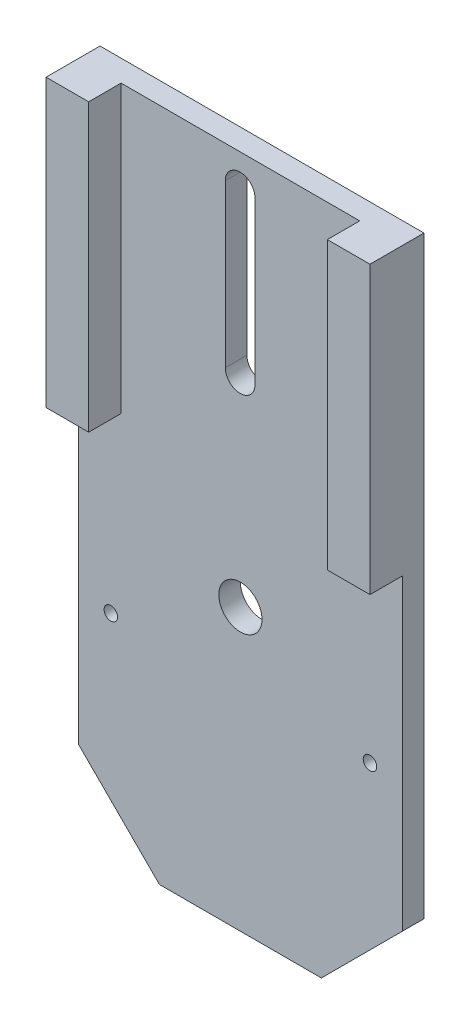
from build123d import *

# Parameters (mm, degrees)
ESQUISSE1_W             = 60
ESQUISSE1_H             = 125
BOSS_EXTRU_1_DEPTH      = 10
ESQUISSE2_R             = 4
ENL_V_MAT_EXTRU_1_DEPTH = 11
ESQUISSE4_W             = 6
ESQUISSE4_H             = 72
ENL_V_MAT_EXTRU_2_DEPTH = 61
TROU_TARAUD_M33_D       = 2.5
TROU_TARAUD_M34_D       = 2.5
CHANFREIN1_SIZE         = 15
ESQUISSE15_W            = 44.2
ESQUISSE15_H            = 6
ENL_V_MAT_EXTRU_4_DEPTH = 55
ENL_V_MAT_EXTRU_5_DEPTH = 11


with BuildPart() as part:
    # Esquisse1 → Boss.-Extru.1 (new body)
    with BuildSketch(Plane.XY):
        with Locations((30, 62.5)):
            Rectangle(ESQUISSE1_W, ESQUISSE1_H)
    extrude(amount=BOSS_EXTRU_1_DEPTH)

    # Esquisse2 → Enlèv. mat.-Extru.1 (cut, through all)
    with BuildSketch(Plane.XY.offset(10)):
        with Locations((30, 52)):
            Circle(ESQUISSE2_R)
    extrude(amount=-ENL_V_MAT_EXTRU_1_DEPTH, mode=Mode.SUBTRACT)

    # Esquisse4 → Enlèv. mat.-Extru.2 (cut, through all)
    with BuildSketch(Plane.ZY):
        with Locations((7, 36)):
            Rectangle(ESQUISSE4_W, ESQUISSE4_H)
    extrude(amount=-ENL_V_MAT_EXTRU_2_DEPTH, mode=Mode.SUBTRACT)

    # Trou taraudé M33 (through all)
    with Locations(Plane.XY.offset(4)):
        with Locations((54, 39)):
            Hole(TROU_TARAUD_M33_D / 2)

    # Trou taraudé M34 (through all)
    with Locations(Plane.XY.offset(4)):
        with Locations((6, 39)):
            Hole(TROU_TARAUD_M34_D / 2)

    # Chanfrein1
    chanfrein1_edges = [part.edges().sort_by_distance(p)[0] for p in [
        (60, 0, 2),
        (0, 0, 2),
    ]]
    chamfer(chanfrein1_edges, length=CHANFREIN1_SIZE)

    # Esquisse15 → Enlèv. mat.-Extru.4 (cut)
    with BuildSketch(Plane(origin=(0, 125, 0), x_dir=(1, 0, 0), z_dir=(0, 1, 0))):
        with Locations((30, -7)):
            Rectangle(ESQUISSE15_W, ESQUISSE15_H)
    extrude(amount=-ENL_V_MAT_EXTRU_4_DEPTH, mode=Mode.SUBTRACT)

    # Esquisse16 → Enlèv. mat.-Extru.5 (cut, through all)
    with BuildSketch(Plane(origin=(0, 0, 0), x_dir=(-1, 0, 0), z_dir=(0, 0, -1))):
        with BuildLine():
            Line((-27.202577742, 119), (-27.202577742, 89))
            ThreePointArc((-27.202577742, 89), (-29.952577742, 86.25), (-32.702577742, 89))
            Line((-32.702577742, 89), (-32.702577742, 119))
            ThreePointArc((-32.702577742, 119), (-29.952577742, 121.75), (-27.202577742, 119))
        make_face()
    extrude(amount=-ENL_V_MAT_EXTRU_5_DEPTH, mode=Mode.SUBTRACT)


solid = part.part
